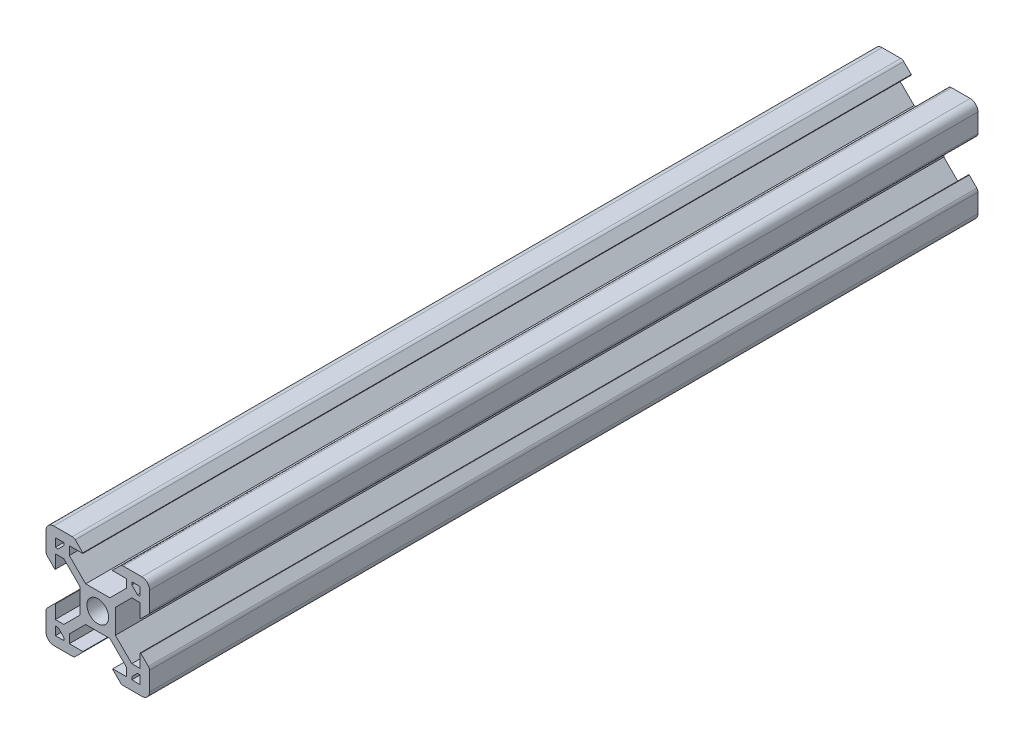
from build123d import *

# Parameters (mm, degrees)
SKETCH6_R           = 2.1
BOSS_EXTRUDE1_DEPTH = 160


with BuildPart() as part:
    # Sketch6 → Boss-Extrude1 (new body)
    with BuildSketch(Plane.XY):
        with BuildLine():
            Line((-3.4, -2.339339828), (-3.4, 2.339339828))
            Line((-3.4, 2.339339828), (-6.560660172, 5.5))
            Line((-6.560660172, 5.5), (-8.2, 5.5))
            Line((-8.2, 5.5), (-8.2, 2.89))
            Line((-8.2, 2.89), (-8.31, 2.89))
            Line((-8.31, 2.89), (-9.768614357, 4.348614357))
            ThreePointArc((-9.768614357, 4.348614357), (-9.939864831, 4.604908803), (-10, 4.907228714))
            Line((-10, 4.907228714), (-10, 8.5))
            ThreePointArc((-10, 8.5), (-9.560660172, 9.560660172), (-8.5, 10))
            Line((-8.5, 10), (-4.907228714, 10))
            ThreePointArc((-4.907228714, 10), (-4.604908803, 9.939864831), (-4.348614357, 9.768614357))
            Line((-4.348614357, 9.768614357), (-2.89, 8.31))
            Line((-2.89, 8.31), (-2.89, 8.2))
            Line((-2.89, 8.2), (-5.5, 8.2))
            Line((-5.5, 8.2), (-5.5, 6.560660172))
            Line((-5.5, 6.560660172), (-2.339339828, 3.4))
            Line((-2.339339828, 3.4), (2.339339828, 3.4))
            Line((2.339339828, 3.4), (5.5, 6.560660172))
            Line((5.5, 6.560660172), (5.5, 8.2))
            Line((5.5, 8.2), (2.89, 8.2))
            Line((2.89, 8.2), (2.89, 8.31))
            Line((2.89, 8.31), (4.348614357, 9.768614357))
            ThreePointArc((4.348614357, 9.768614357), (4.604908803, 9.939864831), (4.907228714, 10))
            Line((4.907228714, 10), (8.5, 10))
            ThreePointArc((8.5, 10), (9.560660172, 9.560660172), (10, 8.5))
            Line((10, 8.5), (10, 4.907228714))
            ThreePointArc((10, 4.907228714), (9.939864831, 4.604908803), (9.768614357, 4.348614357))
            Line((9.768614357, 4.348614357), (8.31, 2.89))
            Line((8.31, 2.89), (8.2, 2.89))
            Line((8.2, 2.89), (8.2, 5.5))
            Line((8.2, 5.5), (6.560660172, 5.5))
            Line((6.560660172, 5.5), (3.4, 2.339339828))
            Line((3.4, 2.339339828), (3.4, -2.339339828))
            Line((3.4, -2.339339828), (6.560660172, -5.5))
            Line((6.560660172, -5.5), (8.2, -5.5))
            Line((8.2, -5.5), (8.2, -2.89))
            Line((8.2, -2.89), (8.31, -2.89))
            Line((8.31, -2.89), (9.768614357, -4.348614357))
            ThreePointArc((9.768614357, -4.348614357), (9.939864831, -4.604908803), (10, -4.907228714))
            Line((10, -4.907228714), (10, -8.5))
            ThreePointArc((10, -8.5), (9.560660172, -9.560660172), (8.5, -10))
            Line((8.5, -10), (4.907228714, -10))
            ThreePointArc((4.907228714, -10), (4.604908803, -9.939864831), (4.348614357, -9.768614357))
            Line((4.348614357, -9.768614357), (2.89, -8.31))
            Line((2.89, -8.31), (2.89, -8.2))
            Line((2.89, -8.2), (5.5, -8.2))
            Line((5.5, -8.2), (5.5, -6.560660172))
            Line((5.5, -6.560660172), (2.339339828, -3.4))
            Line((2.339339828, -3.4), (-2.339339828, -3.4))
            Line((-2.339339828, -3.4), (-5.5, -6.560660172))
            Line((-5.5, -6.560660172), (-5.5, -8.2))
            Line((-5.5, -8.2), (-2.89, -8.2))
            Line((-2.89, -8.2), (-2.89, -8.31))
            Line((-2.89, -8.31), (-4.348614357, -9.768614357))
            ThreePointArc((-4.348614357, -9.768614357), (-4.604908803, -9.939864831), (-4.907228714, -10))
            Line((-4.907228714, -10), (-8.5, -10))
            ThreePointArc((-8.5, -10), (-9.560660172, -9.560660172), (-10, -8.5))
            Line((-10, -8.5), (-10, -4.907228714))
            ThreePointArc((-10, -4.907228714), (-9.939864831, -4.604908803), (-9.768614357, -4.348614357))
            Line((-9.768614357, -4.348614357), (-8.31, -2.89))
            Line((-8.31, -2.89), (-8.2, -2.89))
            Line((-8.2, -2.89), (-8.2, -5.5))
            Line((-8.2, -5.5), (-6.560660172, -5.5))
            Line((-6.560660172, -5.5), (-3.4, -2.339339828))
        make_face()
        Circle(SKETCH6_R, mode=Mode.SUBTRACT)
        Polygon((-7.66, 6.57), (-6.57, 7.66), (-6.57, 8.2), (-8.2, 8.2), (-8.2, 6.57), align=None, mode=Mode.SUBTRACT)
        Polygon((8.2, 6.57), (7.66, 6.57), (6.57, 7.66), (6.57, 8.2), (8.2, 8.2), align=None, mode=Mode.SUBTRACT)
        Polygon((7.66, -6.57), (6.57, -7.66), (6.57, -8.2), (8.2, -8.2), (8.2, -6.57), align=None, mode=Mode.SUBTRACT)
        Polygon((-8.2, -6.57), (-7.66, -6.57), (-6.57, -7.66), (-6.57, -8.2), (-8.2, -8.2), align=None, mode=Mode.SUBTRACT)
    extrude(amount=-BOSS_EXTRUDE1_DEPTH)


solid = part.part
